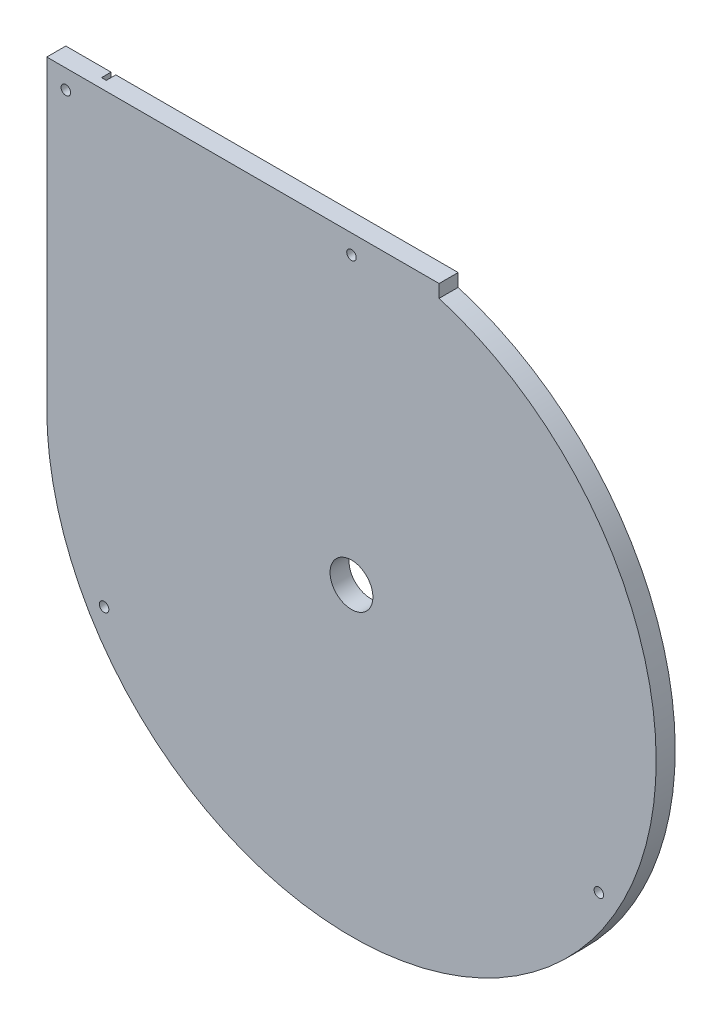
from build123d import *

# Parameters (mm, degrees)
SKETCH1_W           = 406.4
SKETCH1_H           = 406.4
BOSS_EXTRUDE1_DEPTH = 12.7
CUT_EXTRUDE1_DEPTH  = 6.35
SKETCH3_R           = 14.2875
CUT_EXTRUDE2_DEPTH  = 13.7
SKETCH4_R           = 3.175
CUT_EXTRUDE3_DEPTH  = 13.7


with BuildPart() as part:
    # Sketch1 → Boss-Extrude1 (new body)
    with BuildSketch(Plane.XY):
        Rectangle(SKETCH1_W, SKETCH1_H)
    extrude(amount=BOSS_EXTRUDE1_DEPTH)

    # Sketch2 → Cut-Extrude1 (cut)
    with BuildSketch(Plane(origin=(0, 0, 0), x_dir=(-1, 0, 0), z_dir=(0, 0, -1))):
        with BuildLine():
            Line((17.696900373, 168.938120694), (18.027683557, 172.095842576))
            ThreePointArc((18.027683557, 172.095842576), (-128.571850923, -115.806975422), (173.0375, 0))
            Line((173.0375, 0), (173.0375, 203.2))
            Line((173.0375, 203.2), (169.8625, 203.2))
            Line((169.8625, 203.2), (169.8625, 0))
            ThreePointArc((169.8625, 0), (-126.212734393, -113.68207679), (17.696900373, 168.938120694))
        make_face()
    extrude(amount=-CUT_EXTRUDE1_DEPTH, mode=Mode.SUBTRACT)

    # Sketch3 → Cut-Extrude2 (cut, through all)
    with BuildSketch(Plane(origin=(0, 0, 0), x_dir=(-1, 0, 0), z_dir=(0, 0, -1))):
        with BuildLine():
            ThreePointArc((203.2, 0), (143.684097941, -143.684097933), (1.1e-08, -203.2))
            Line((1.1e-08, -203.2), (203.2, -203.2))
            Line((203.2, -203.2), (203.2, 0))
        make_face()
        with BuildLine():
            ThreePointArc((1.1e-08, -203.2), (-143.684098268, -143.684097606), (-203.2, 9.47e-07))
            Line((-203.2, 9.47e-07), (-203.2, -203.2))
            Line((-203.2, -203.2), (1.1e-08, -203.2))
        make_face()
        with BuildLine():
            ThreePointArc((-203.2, 9.47e-07), (-163.039512773, 121.278016454), (-58.432704894, 194.617211466))
            Line((-58.432704894, 194.617211466), (-58.432704894, 203.2))
            Line((-58.432704894, 203.2), (-203.2, 203.2))
            Line((-203.2, 203.2), (-203.2, 9.47e-07))
        make_face()
        Circle(SKETCH3_R)
    extrude(amount=-CUT_EXTRUDE2_DEPTH, mode=Mode.SUBTRACT)

    # Sketch4 → Cut-Extrude3 (cut, through all)
    with BuildSketch(Plane(origin=(0, 0, 0), x_dir=(-1, 0, 0), z_dir=(0, 0, -1))):
        with Locations((-164.977839421, -95.25)):
            Circle(SKETCH4_R)
        with Locations((0, 190.5)):
            Circle(SKETCH4_R)
        with Locations((164.977839421, -95.25)):
            Circle(SKETCH4_R)
        with Locations((190.5, 190.5)):
            Circle(SKETCH4_R)
    extrude(amount=-CUT_EXTRUDE3_DEPTH, mode=Mode.SUBTRACT)


solid = part.part
